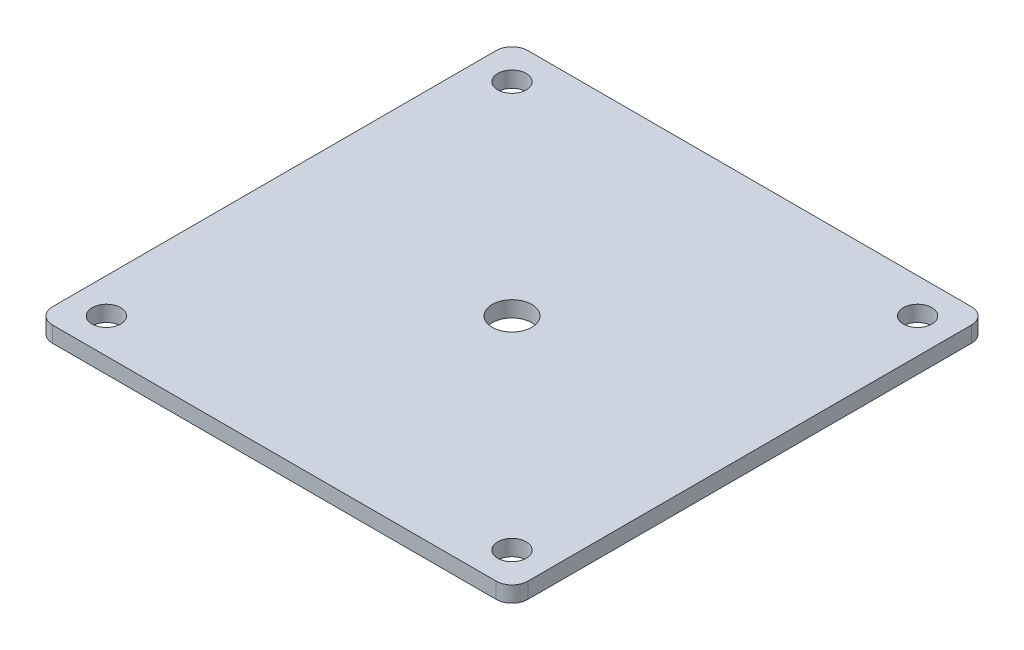
from build123d import *

# Parameters (mm, degrees)
SKETCH2_W           = 76.2
SKETCH2_H           = 76.2
BOSS_EXTRUDE2_DEPTH = 2.54
SKETCH5_R           = 2.286
CUT_EXTRUDE1_DEPTH  = 2.54
SKETCH6_R           = 3.175
CUT_EXTRUDE2_DEPTH  = 2.54
FILLET3_R           = 2.54


with BuildPart() as part:
    # Sketch2 → Boss-Extrude2 (new body)
    with BuildSketch(Plane(origin=(0, 0, 0), x_dir=(1, 0, 0), z_dir=(0, 1, 0))):
        Rectangle(SKETCH2_W, SKETCH2_H)
    extrude(amount=BOSS_EXTRUDE2_DEPTH)

    # Sketch5 → Cut-Extrude1 (cut)
    with BuildSketch(Plane(origin=(0, 2.54, 0), x_dir=(1, 0, 0), z_dir=(0, 1, 0))):
        with Locations((-32.512, 32.512)):
            Circle(SKETCH5_R)
        with Locations((32.512, 32.512)):
            Circle(SKETCH5_R)
        with Locations((32.512, -32.512)):
            Circle(SKETCH5_R)
        with Locations((-32.512, -32.512)):
            Circle(SKETCH5_R)
    extrude(amount=-CUT_EXTRUDE1_DEPTH, mode=Mode.SUBTRACT)

    # Sketch6 → Cut-Extrude2 (cut)
    with BuildSketch(Plane(origin=(0, 2.54, 0), x_dir=(1, 0, 0), z_dir=(0, 1, 0))):
        Circle(SKETCH6_R)
    extrude(amount=-CUT_EXTRUDE2_DEPTH, mode=Mode.SUBTRACT)

    # Fillet3
    fillet3_edges = [part.edges().sort_by_distance(p)[0] for p in [
        (38.1, 1.27, 38.1),
        (-38.1, 1.27, 38.1),
        (-38.1, 1.27, -38.1),
        (38.1, 1.27, -38.1),
    ]]
    fillet(fillet3_edges, radius=FILLET3_R)


solid = part.part
